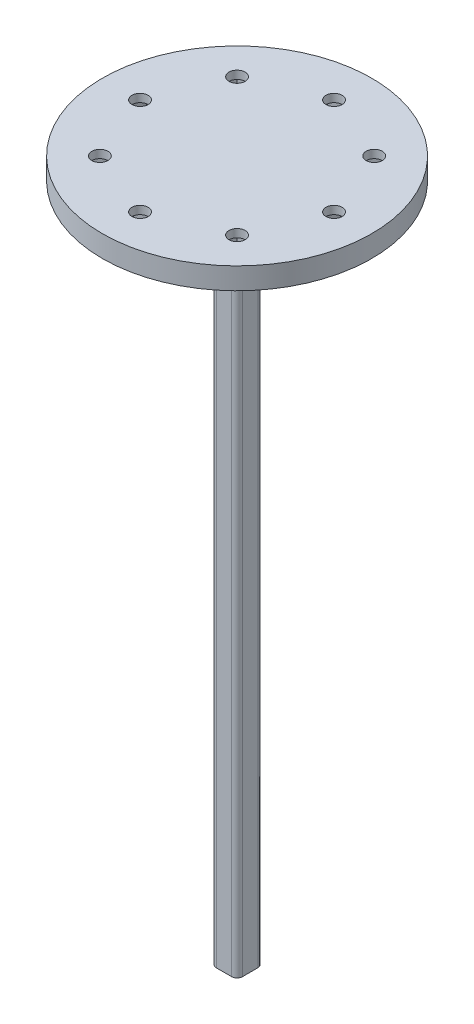
from build123d import *

# Parameters (mm, degrees)
SKETCH_1_R               = 20
EXTRUDE_1_DEPTH          = 4
SKETCH_2_R               = 7.407075634
EXTRUDE_2_DEPTH          = 8
SKETCH_3_W               = 4.85
SKETCH_3_H               = 4.85
EXTRUDE_3_DEPTH          = 118
SKETCH_5_R               = 25
EXTRUDE_4_DEPTH          = 4
CUT_EXTRUDE_1_DEPTH      = 2.5
SKETCH_7_R               = 1.5
CUT_EXTRUDE_2_DEPTH      = 2.5
PATTERN_CIRCULAR_1_COUNT = 8
FILLET_1_R               = 1
SKETCH_9_R               = 25
EXTRUDE_5_DEPTH          = 4
SKETCH_10_R              = 5.5
EXTRUDE_6_DEPTH          = 8
SKETCH_11_W              = 4.85
SKETCH_11_H              = 4.85
EXTRUDE_7_DEPTH          = 118
CUT_EXTRUDE_7_DEPTH      = 128.5
SKETCH_13_R              = 1.5
CUT_EXTRUDE_8_DEPTH      = 128.5
PATTERN_CIRCULAR_2_COUNT = 8
FILLET_2_R               = 1
SKETCH_14_R              = 7.407075634
SKETCH_14_R_2            = 5.5
CUT_EXTRUDE_9_DEPTH      = 8
SKETCH_15_W              = 54.152446135
SKETCH_15_H              = 58.876914062
CUT_EXTRUDE_10_DEPTH     = 130


with BuildPart() as part:
    # 草图1 → 凸台-拉伸1 (new body)
    with BuildSketch(Plane(origin=(0, 0, 0), x_dir=(1, 0, 0), z_dir=(0, 1, 0))):
        Circle(SKETCH_1_R)
    extrude(amount=EXTRUDE_1_DEPTH)

    # 草图2 → 凸台-拉伸2 (add)
    with BuildSketch(Plane.XZ):
        Circle(SKETCH_2_R)
    extrude(amount=EXTRUDE_2_DEPTH)

    # 草图3 → 凸台-拉伸3 (add)
    with BuildSketch(Plane.XZ.offset(8)):
        Rectangle(SKETCH_3_W, SKETCH_3_H)
    extrude(amount=EXTRUDE_3_DEPTH)

    # 草图5 → 凸台-拉伸4 (add)
    with BuildSketch(Plane(origin=(0, 4, 0), x_dir=(1, 0, 0), z_dir=(0, 1, 0))):
        Circle(SKETCH_5_R)
    extrude(amount=-EXTRUDE_4_DEPTH)

    # 草图6 → 切除-拉伸1 (cut)
    with BuildSketch(Plane.XZ):
        Polygon((21.233161507, 0), (19.616580754, 2.8), (16.383419246, 2.8), (14.766838493, 0), (16.383419246, -2.8), (19.616580754, -2.8), align=None)
    cut_extrude_1 = extrude(amount=-CUT_EXTRUDE_1_DEPTH, mode=Mode.SUBTRACT)

    # 草图7 → 切除-拉伸2 (cut)
    with BuildSketch(Plane.XZ.offset(-2.5)):
        with Locations((18, 0)):
            Circle(SKETCH_7_R)
    cut_extrude_2 = extrude(amount=-CUT_EXTRUDE_2_DEPTH, mode=Mode.SUBTRACT)

    # 阵列(圆周)1: 切除-拉伸1, 切除-拉伸2 ×8 about axis
    pattern_circular_1_axis = Axis((0, 0, 0), (0, 1, 0))
    for i in range(1, PATTERN_CIRCULAR_1_COUNT):
        add(cut_extrude_1.rotate(pattern_circular_1_axis, i * 360 / PATTERN_CIRCULAR_1_COUNT), mode=Mode.SUBTRACT)
        add(cut_extrude_2.rotate(pattern_circular_1_axis, i * 360 / PATTERN_CIRCULAR_1_COUNT), mode=Mode.SUBTRACT)

    # 圆角1
    fillet_1_edges = [part.edges().sort_by_distance(p)[0] for p in [
        (2.425, -67, -2.425),
        (2.425, -67, 2.425),
        (-2.425, -67, 2.425),
        (-2.425, -67, -2.425),
    ]]
    fillet(fillet_1_edges, radius=FILLET_1_R)

    # 草图14 → 切除-拉伸9 (cut)
    with BuildSketch(Plane.XZ.offset(8)):
        Circle(SKETCH_14_R)
        Circle(SKETCH_14_R_2, mode=Mode.SUBTRACT)
    extrude(amount=-CUT_EXTRUDE_9_DEPTH, mode=Mode.SUBTRACT)


with BuildPart() as body_2:
    # 草图9 → 凸台-拉伸5 (new body)
    with BuildSketch(Plane(origin=(0, 0, 0), x_dir=(1, 0, 0), z_dir=(0, 1, 0))):
        with Locations((53.487556259, 0)):
            Circle(SKETCH_9_R)
    extrude(amount=EXTRUDE_5_DEPTH)

    # 草图10 → 凸台-拉伸6 (add)
    with BuildSketch(Plane.XZ):
        with Locations((53.487556259, 0)):
            Circle(SKETCH_10_R)
    extrude(amount=EXTRUDE_6_DEPTH)

    # 草图11 → 凸台-拉伸7 (add)
    with BuildSketch(Plane.XZ.offset(8)):
        with Locations((53.487556259, 0)):
            Rectangle(SKETCH_11_W, SKETCH_11_H)
    extrude(amount=EXTRUDE_7_DEPTH)

    # 草图12 → 切除-拉伸7 (cut)
    with BuildSketch(Plane.XZ.offset(126)):
        Polygon((38.720717767, 0), (37.104137013, 2.8), (33.870975506, 2.8), (32.254394752, 0), (33.870975506, -2.8), (37.104137013, -2.8), align=None)
    cut_extrude_7 = extrude(amount=-CUT_EXTRUDE_7_DEPTH, mode=Mode.SUBTRACT)

    # 草图13 → 切除-拉伸8 (cut)
    with BuildSketch(Plane.XZ.offset(-2.5)):
        with Locations((35.487556259, 0)):
            Circle(SKETCH_13_R)
    cut_extrude_8 = extrude(amount=-CUT_EXTRUDE_8_DEPTH, mode=Mode.SUBTRACT)

    # 阵列(圆周)2: 切除-拉伸7, 切除-拉伸8 ×8 about axis
    pattern_circular_2_axis = Axis((53.487556259, 0, 0), (0, 1, 0))
    for i in range(1, PATTERN_CIRCULAR_2_COUNT):
        add(cut_extrude_7.rotate(pattern_circular_2_axis, i * 360 / PATTERN_CIRCULAR_2_COUNT), mode=Mode.SUBTRACT)
        add(cut_extrude_8.rotate(pattern_circular_2_axis, i * 360 / PATTERN_CIRCULAR_2_COUNT), mode=Mode.SUBTRACT)

    # 圆角2
    fillet_2_edges = [body_2.edges().sort_by_distance(p)[0] for p in [
        (55.912556259, -67, -2.425),
        (55.912556259, -67, 2.425),
        (51.062556259, -67, 2.425),
        (51.062556259, -67, -2.425),
    ]]
    fillet(fillet_2_edges, radius=FILLET_2_R)

    # 草图15 → 切除-拉伸10 (cut)
    with BuildSketch(Plane(origin=(0, 4, 0), x_dir=(1, 0, 0), z_dir=(0, 1, 0))):
        with Locations((53.48755626, 0)):
            Rectangle(SKETCH_15_W, SKETCH_15_H)
    extrude(amount=-CUT_EXTRUDE_10_DEPTH, mode=Mode.SUBTRACT)


solid = part.part
